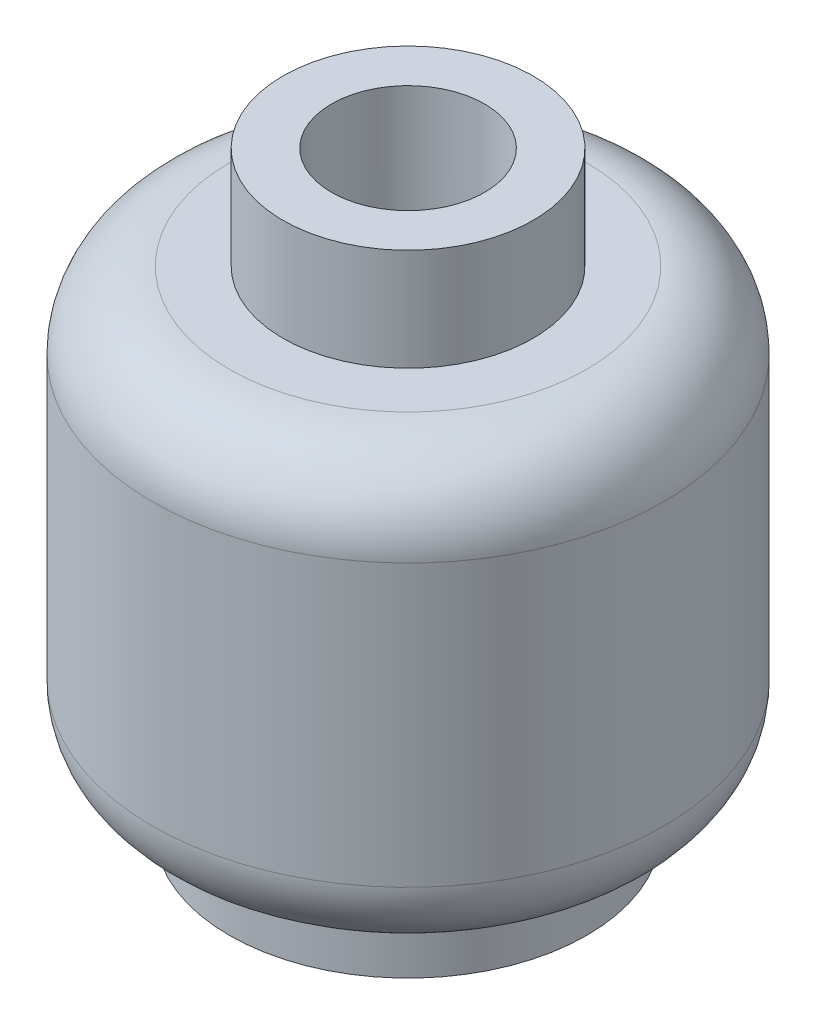
from build123d import *

# Parameters (mm, degrees)
SKETCH8_R               = 2.55
CUT_EXTRUDE1_DEPTH      = 8.5
CUT_EXTRUDE1_DRAFT      = -1
SKETCH9_R               = 1.5
CUT_EXTRUDE2_DEPTH      = 2
CUT_EXTRUDE5_DEPTH      = 12.923087
CUT_EXTRUDE5_DEPTH_BACK = 12.923087


with BuildPart() as part:
    # Sketch1 → Revolve1 (revolve)
    with BuildSketch(Plane.XY):
        with BuildLine():
            Line((0, 45.7875), (2.45, 45.7875))
            Line((2.45, 45.7875), (2.45, 43.7875))
            Line((2.45, 43.7875), (3.5, 43.7875))
            ThreePointArc((3.5, 43.7875), (4.56066, 43.34816), (5, 42.2875))
            Line((5, 42.2875), (5, 36.7875))
            ThreePointArc((5, 36.7875), (4.56066, 35.726839), (3.5, 35.2875))
            Line((3.5, 35.2875), (3.5, 34.1875))
            Line((3.5, 34.1875), (0, 34.1875))
            Line((0, 34.1875), (0, 45.7875))
        make_face()
    revolve(axis=Axis((0, 45.7875, 0), (0, -1, 0)))


with BuildPart() as cut_extrude1_tool:
    # Sketch8 → Cut-Extrude1 (with draft: the straight prism first)
    with BuildSketch(Plane.XZ.offset(-34.1875)):
        Circle(SKETCH8_R)
    extrude(amount=-CUT_EXTRUDE1_DEPTH)
    # Cut-Extrude1: the draft: its side faces are tilted about the plane it starts from
    cut_extrude1_sides = [cut_extrude1_tool.faces().sort_by_distance(p)[0] for p in [
        (-2.55, 38.4375, 0),
    ]]
    draft(cut_extrude1_sides, Plane.XZ.offset(-34.1875), CUT_EXTRUDE1_DRAFT)


with BuildPart() as part_1:
    add(part.part)

    # Cut-Extrude1: cut by cut_extrude1_tool
    add(cut_extrude1_tool.part, mode=Mode.SUBTRACT)

    # Sketch9 → Cut-Extrude2 (cut)
    with BuildSketch(Plane(origin=(0, 45.7875, 0), x_dir=(1, 0, 0), z_dir=(0, 1, 0))):
        Circle(SKETCH9_R)
    extrude(amount=-CUT_EXTRUDE2_DEPTH, mode=Mode.SUBTRACT)

    # Sketch10 → Cut-Extrude5 (cut, two sides: drawn at the far end of the back side and taken through both)
    with BuildSketch(Plane(origin=(0, 43.7875, 0), x_dir=(1, 0, 0), z_dir=(0, 1, 0)).offset(-CUT_EXTRUDE5_DEPTH_BACK)):
        with BuildLine():
            Line((-0.4, 0.349857), (-0.4, 1.445683))
            ThreePointArc((-0.4, 1.445683), (-1.271196, 0.796279), (-1.47532, -0.27098))
            Line((-1.47532, -0.27098), (-0.4, 0.349857))
        make_face()
        with BuildLine():
            ThreePointArc((1.47532, -0.27098), (1.271196, 0.796279), (0.4, 1.445683))
            Line((0.4, 1.445683), (0.4, 0.349857))
            Line((0.4, 0.349857), (1.47532, -0.27098))
        make_face()
        with BuildLine():
            Line((0, -0.342964), (-1.12481, -0.992373))
            ThreePointArc((-1.12481, -0.992373), (0, -1.5), (1.12481, -0.992373))
            Line((1.12481, -0.992373), (0, -0.342964))
        make_face()
    extrude(amount=CUT_EXTRUDE5_DEPTH + CUT_EXTRUDE5_DEPTH_BACK, mode=Mode.SUBTRACT)


solid = part_1.part
